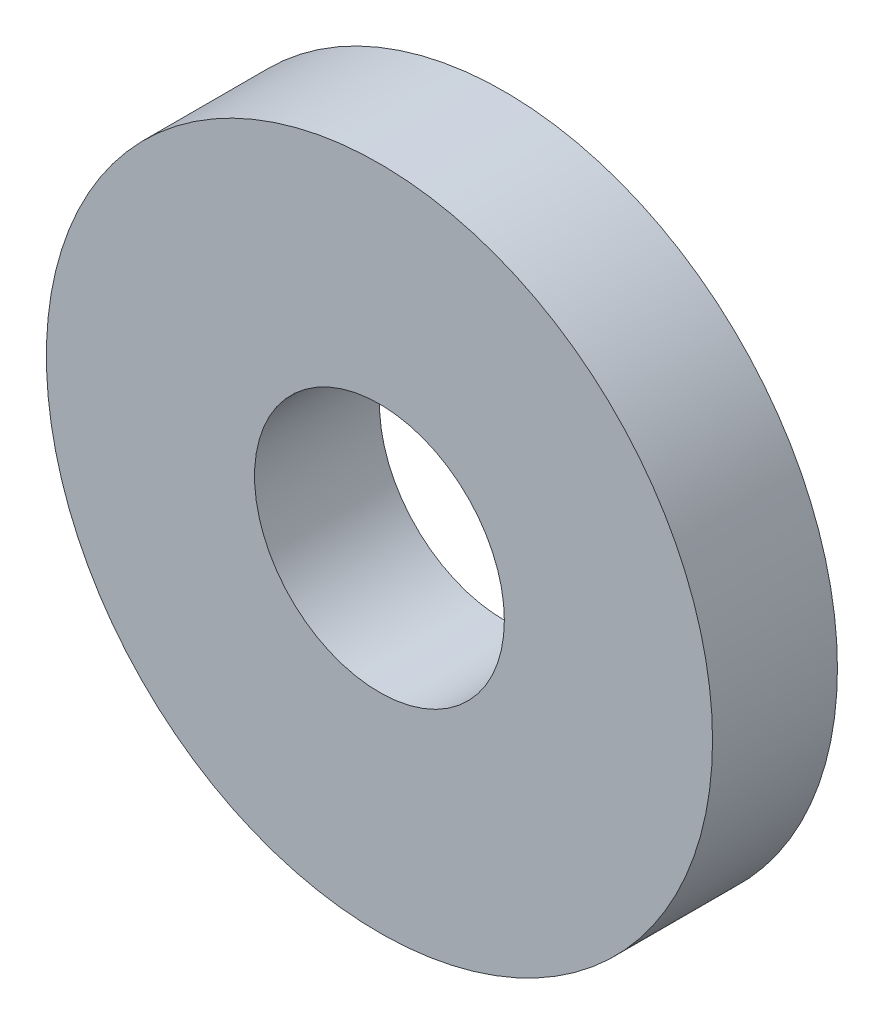
from build123d import *

# Parameters (mm, degrees)
SKETCH1_R           = 50.8
SKETCH1_R_2         = 19.05
BOSS_EXTRUDE1_DEPTH = 19.05


with BuildPart() as part:
    # Sketch1 → Boss-Extrude1 (new body)
    with BuildSketch(Plane.XY):
        Circle(SKETCH1_R)
        Circle(SKETCH1_R_2, mode=Mode.SUBTRACT)
    extrude(amount=BOSS_EXTRUDE1_DEPTH)


solid = part.part
